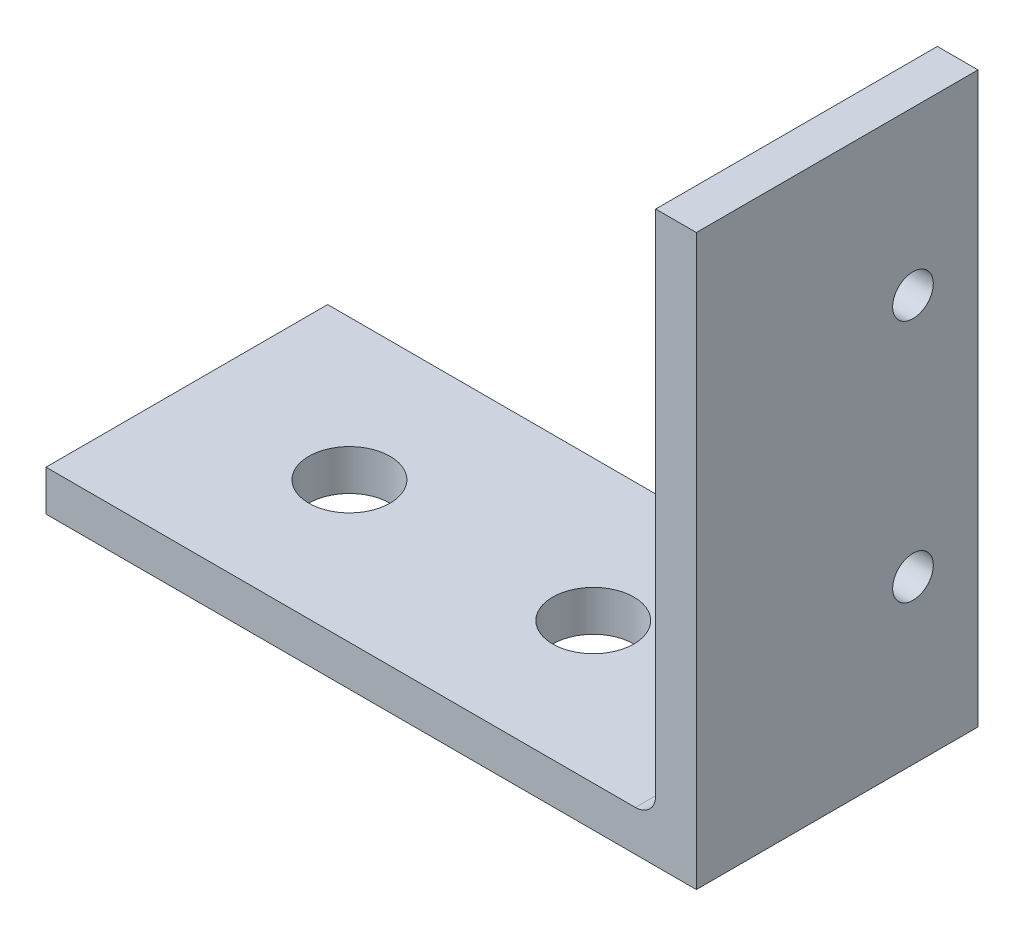
from build123d import *

# Parameters (mm, degrees)
BOSS_EXTRUDE1_DEPTH = 11
FILLET1_R           = 1.5875
SKETCH3_W           = 24.423912887
SKETCH3_H           = 26.552361768
CUT_EXTRUDE1_DEPTH  = 23
SKETCH4_R           = 3.175
CUT_EXTRUDE2_DEPTH  = 45.45
SKETCH5_R           = 1.5875
CUT_EXTRUDE3_DEPTH  = 51.8


with BuildPart() as part:
    # Sketch2 → Boss-Extrude1 (new body, symmetric)
    with BuildSketch(Plane.XY):
        Polygon((-25.4, 0), (25.4, 0), (25.4, 50.8), (22.225, 50.8), (22.225, 3.175), (-25.4, 3.175), align=None)
    extrude(amount=BOSS_EXTRUDE1_DEPTH, both=True)

    # Fillet1
    fillet1_edges = [part.edges().sort_by_distance(p)[0] for p in [
        (22.225, 3.175, 0),
    ]]
    fillet(fillet1_edges, radius=FILLET1_R)

    # Sketch3 → Cut-Extrude1 (cut, through all)
    with BuildSketch(Plane.XY.offset(11)):
        with Locations((18.271034128, 57.726180884)):
            Rectangle(SKETCH3_W, SKETCH3_H)
    extrude(amount=-CUT_EXTRUDE1_DEPTH, mode=Mode.SUBTRACT)

    # Sketch4 → Cut-Extrude2 (cut, through all)
    with BuildSketch(Plane.XZ):
        with Locations((-12.7, 0)):
            Circle(SKETCH4_R)
        with Locations((6.35, 0)):
            Circle(SKETCH4_R)
    extrude(amount=-CUT_EXTRUDE2_DEPTH, mode=Mode.SUBTRACT)

    # Sketch5 → Cut-Extrude3 (cut, through all)
    with BuildSketch(Plane(origin=(25.4, 0, 0), x_dir=(0, 0, -1), z_dir=(1, 0, 0))):
        with Locations((5.92, 31.75)):
            Circle(SKETCH5_R)
        with Locations((5.92, 12.7)):
            Circle(SKETCH5_R)
    extrude(amount=-CUT_EXTRUDE3_DEPTH, mode=Mode.SUBTRACT)


solid = part.part
